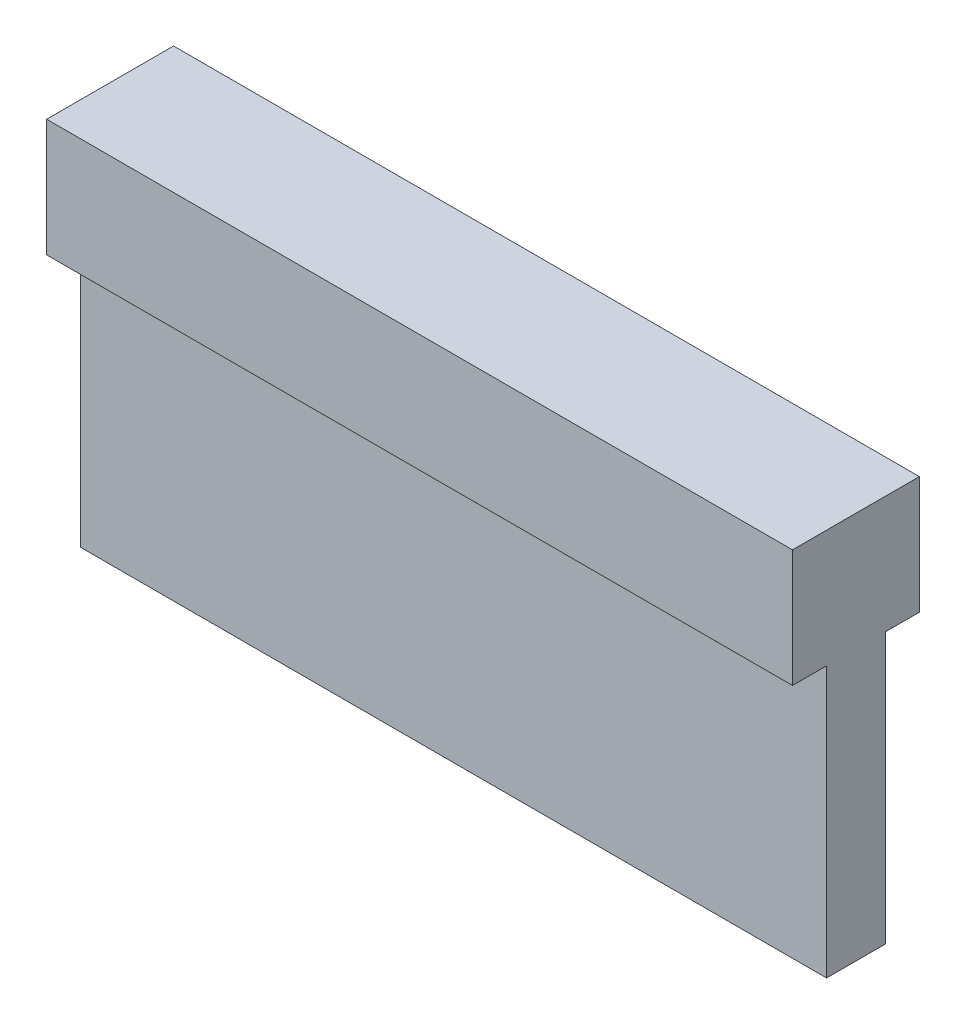
from build123d import *

# Parameters (mm, degrees)
BOSS_EXTRUDE1_DEPTH = 31.75


with BuildPart() as part:
    # Sketch1 → Boss-Extrude1 (new body)
    with BuildSketch(Plane(origin=(0, 0, 0), x_dir=(0, 0, -1), z_dir=(1, 0, 0))):
        Polygon((-1.25, -2.5), (-1.25, -14.01), (1.25, -14.01), (1.25, -2.5), (2.7, -2.5), (2.7, 2.5), (-2.7, 2.5), (-2.7, -2.5), align=None)
    extrude(amount=BOSS_EXTRUDE1_DEPTH)


solid = part.part
